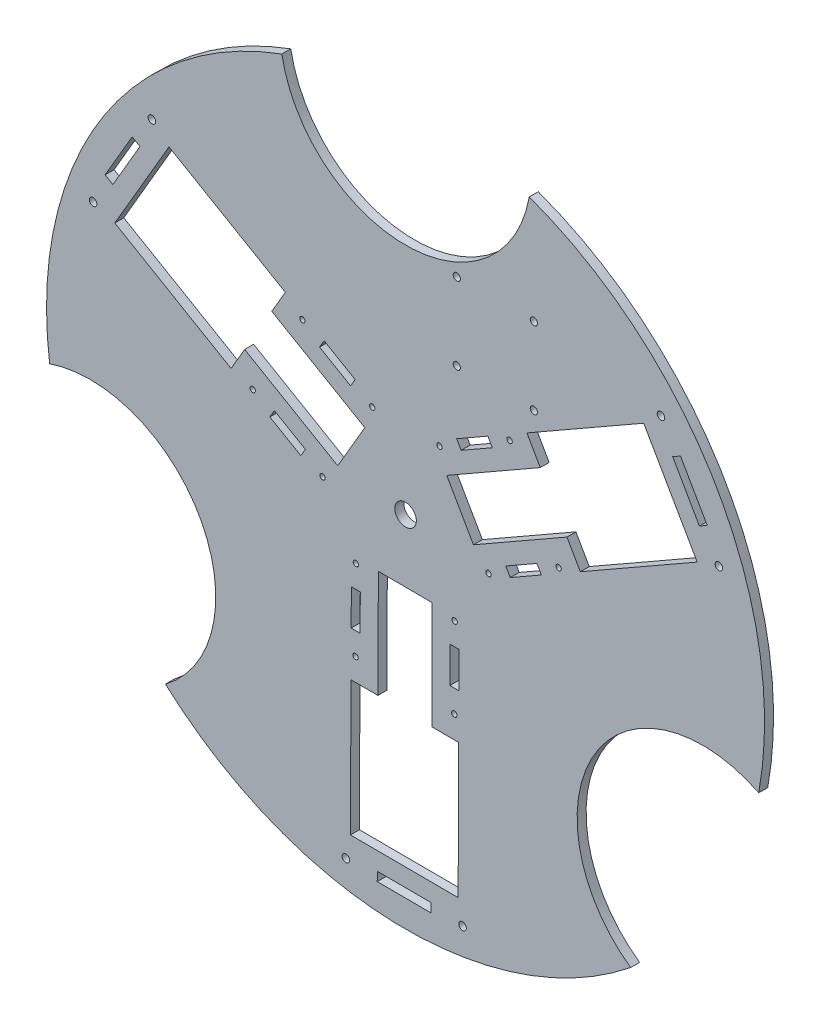
from build123d import *

# Parameters (mm, degrees)
BOSS_EXTRUDE1_DEPTH = 5
SKETCH2_R           = 6
CUT_EXTRUDE1_DEPTH  = 6
CUT_EXTRUDE3_DEPTH  = 6
SKETCH4_R           = 1.5
CUT_EXTRUDE4_DEPTH  = 6
SKETCH5_R           = 2
CUT_EXTRUDE5_DEPTH  = 6
SKETCH6_R           = 2.1
CUT_EXTRUDE6_DEPTH  = 6


with BuildPart() as part:
    # Sketch1 → Boss-Extrude1 (new body)
    with BuildSketch(Plane.XY):
        with BuildLine():
            ThreePointArc((-133.768727702, -148.680622439), (-5.497740296, -199.924422849), (125.395583095, -155.807405923))
            ThreePointArc((125.395583095, -155.807405923), (105.414180622, -62.702389546), (196.766071989, -35.820565518))
            ThreePointArc((196.766071989, -35.820565518), (173.617953569, 99.281449418), (68.919790336, 187.75))
            ThreePointArc((68.919790336, 187.75), (0, 130), (-68.919790336, 187.75))
            ThreePointArc((-68.919790336, 187.75), (-171.192781262, 103.407116021), (-198.254420354, -26.366357541))
            ThreePointArc((-198.254420354, -26.366357541), (-113.788656518, -59.99087954), (-133.768727702, -148.680622439))
        make_face()
    extrude(amount=BOSS_EXTRUDE1_DEPTH)

    # Sketch2 → Cut-Extrude1 (cut, through all)
    with BuildSketch(Plane.XY.offset(5)):
        Circle(SKETCH2_R)
    extrude(amount=-CUT_EXTRUDE1_DEPTH, mode=Mode.SUBTRACT)

    # Sketch3 → Cut-Extrude3 (cut, through all)
    with BuildSketch(Plane.XY.offset(5)):
        Polygon((-131.763323944, 111.527693705), (-66.967361155, 73.758881092), (-74.521123677, 60.799688534), (-22.684353446, 30.584638444), (-37.791878491, 4.666253328), (-89.628648723, 34.881303419), (-97.182411245, 21.922110861), (-161.978374035, 59.690923474), align=None)
        Polygon((162.467477946, 58.34653897), (97.360745358, 21.115995438), (89.914636652, 34.137341956), (37.829250581, 4.352907131), (22.937033168, 30.395600166), (75.022419239, 60.180034991), (67.576310532, 73.201381509), (132.683043121, 110.431925041), align=None)
        Polygon((-30.704154002, -169.874232675), (-30.393384203, -94.874876531), (-15.393512974, -94.93703049), (-15.144897135, -34.937545574), (14.854845323, -35.061853494), (14.606229484, -95.06133841), (29.606100713, -95.12349237), (29.295330914, -170.122848514), align=None)
    extrude(amount=-CUT_EXTRUDE3_DEPTH, mode=Mode.SUBTRACT)

    # Sketch4 → Cut-Extrude4 (cut, through all)
    with BuildSketch(Plane.XY.offset(5)):
        with Locations((-57.426994444, 65.304213564)):
            Circle(SKETCH4_R)
        with Locations((-18.54941677, 42.642925996)):
            Circle(SKETCH4_R)
        with Locations((-46.246546019, -4.874113383)):
            Circle(SKETCH4_R)
        with Locations((-85.124123693, 17.787174185)):
            Circle(SKETCH4_R)
        with Locations((85.268605142, 17.081129269)):
            Circle(SKETCH4_R)
        with Locations((46.204565589, -5.25719685)):
            Circle(SKETCH4_R)
        with Locations((18.902166999, 42.487740382)):
            Circle(SKETCH4_R)
        with Locations((57.966206552, 64.826066501)):
            Circle(SKETCH4_R)
        with Locations((-27.841610699, -82.385342833)):
            Circle(SKETCH4_R)
        with Locations((-27.655148819, -37.385729146)):
            Circle(SKETCH4_R)
        with Locations((27.34437902, -37.613626999)):
            Circle(SKETCH4_R)
        with Locations((27.157917141, -82.613240686)):
            Circle(SKETCH4_R)
        Polygon((-75.583756982, 9.332506656), (-73.065836141, 13.652237509), (-55.786912731, 3.580554145), (-58.304833571, -0.739176707), align=None)
        Polygon((-47.886627732, 56.849546035), (-45.368706892, 61.169276888), (-28.089783481, 51.097593524), (-30.607704322, 46.777862672), align=None)
        Polygon((45.874066336, 60.791200332), (48.356102572, 56.450751492), (30.994307215, 46.522606551), (28.512270979, 50.86305539), align=None)
        Polygon((73.176464926, 13.0462631), (75.658501162, 8.705814261), (58.296705805, -1.222330681), (55.814669569, 3.118118158), align=None)
        Polygon((29.709690646, -70.123706988), (24.709733569, -70.102989001), (24.792605516, -50.103160696), (29.792562592, -50.123878683), align=None)
        Polygon((-25.289837194, -69.895809136), (-30.28979427, -69.875091149), (-30.206922324, -49.875262844), (-25.206965248, -49.89598083), align=None)
    extrude(amount=-CUT_EXTRUDE4_DEPTH, mode=Mode.SUBTRACT)

    # Sketch5 → Cut-Extrude5 (cut, through all)
    with BuildSketch(Plane.XY.offset(5)):
        with Locations((71.464466094, 128.964466094)):
            Circle(SKETCH5_R)
        with Locations((71.464466094, 86.035533906)):
            Circle(SKETCH5_R)
        with Locations((28.535533906, 86.035533906)):
            Circle(SKETCH5_R)
        with Locations((28.535533906, 128.964466094)):
            Circle(SKETCH5_R)
    extrude(amount=-CUT_EXTRUDE5_DEPTH, mode=Mode.SUBTRACT)

    # Sketch6 → Cut-Extrude6 (cut, through all)
    with BuildSketch(Plane(origin=(0, 0, 0), x_dir=(-1, 0, 0), z_dir=(0, 0, -1))):
        with Locations((141.303690655, 119.982361234)):
            Circle(SKETCH6_R)
        with Locations((174.036661587, 63.825860149)):
            Circle(SKETCH6_R)
        with Locations((33.255927507, -182.363766373)):
            Circle(SKETCH6_R)
        with Locations((-31.743514485, -182.633100198)):
            Circle(SKETCH6_R)
        with Locations((-174.559618162, 62.381405139)):
            Circle(SKETCH6_R)
        with Locations((-142.293147101, 118.807240049)):
            Circle(SKETCH6_R)
        Polygon((-148.810049506, 102.374650994), (-153.150498345, 104.85668723), (-168.042715757, 78.813994194), (-163.702266918, 76.331957959), align=None)
        Polygon((163.064073217, 77.685957713), (167.38380407, 80.203878554), (152.276279025, 106.12226367), (147.956548172, 103.604342829), align=None)
        Polygon((-14.254023712, -180.060608707), (-14.233305725, -185.060565784), (15.766436733, -184.936257864), (15.745718746, -179.936300788), align=None)
    extrude(amount=-CUT_EXTRUDE6_DEPTH, mode=Mode.SUBTRACT)


solid = part.part
